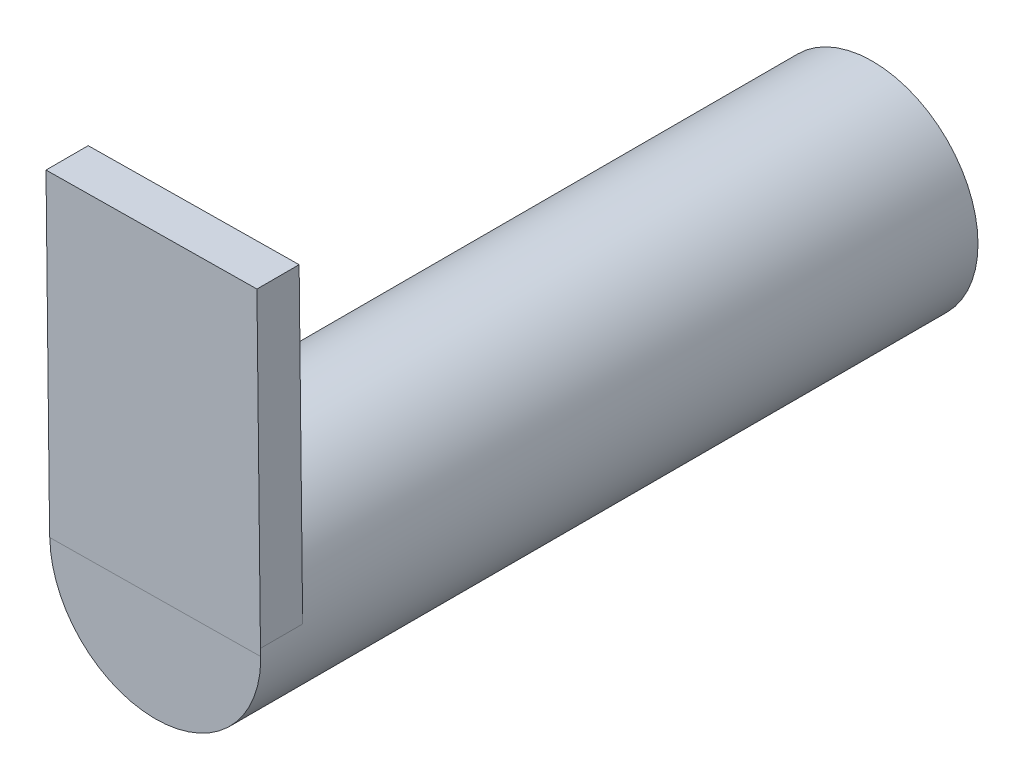
from build123d import *

# Parameters (mm, degrees)
SKETCH1_R           = 5
BOSS_EXTRUDE1_DEPTH = 34
SKETCH3_W           = 10
SKETCH3_H           = 2
BOSS_EXTRUDE2_DEPTH = 15


with BuildPart() as part:
    # Sketch1 → Boss-Extrude1 (new body)
    with BuildSketch(Plane.XY):
        with Locations((-14.936060675, 10.217847077)):
            Circle(SKETCH1_R)
    extrude(amount=BOSS_EXTRUDE1_DEPTH)

    # Sketch3 → Boss-Extrude2 (add)
    with BuildSketch(Plane(origin=(-0.118548513, 10.386962355, 0), x_dir=(0.9999348757579138, 0.011412459989218575, 0), z_dir=(-0.011412459989218575, 0.999934875757914, 0))):
        with Locations((-14.829416568, -33.000036039)):
            Rectangle(SKETCH3_W, SKETCH3_H)
    extrude(amount=BOSS_EXTRUDE2_DEPTH)


solid = part.part
